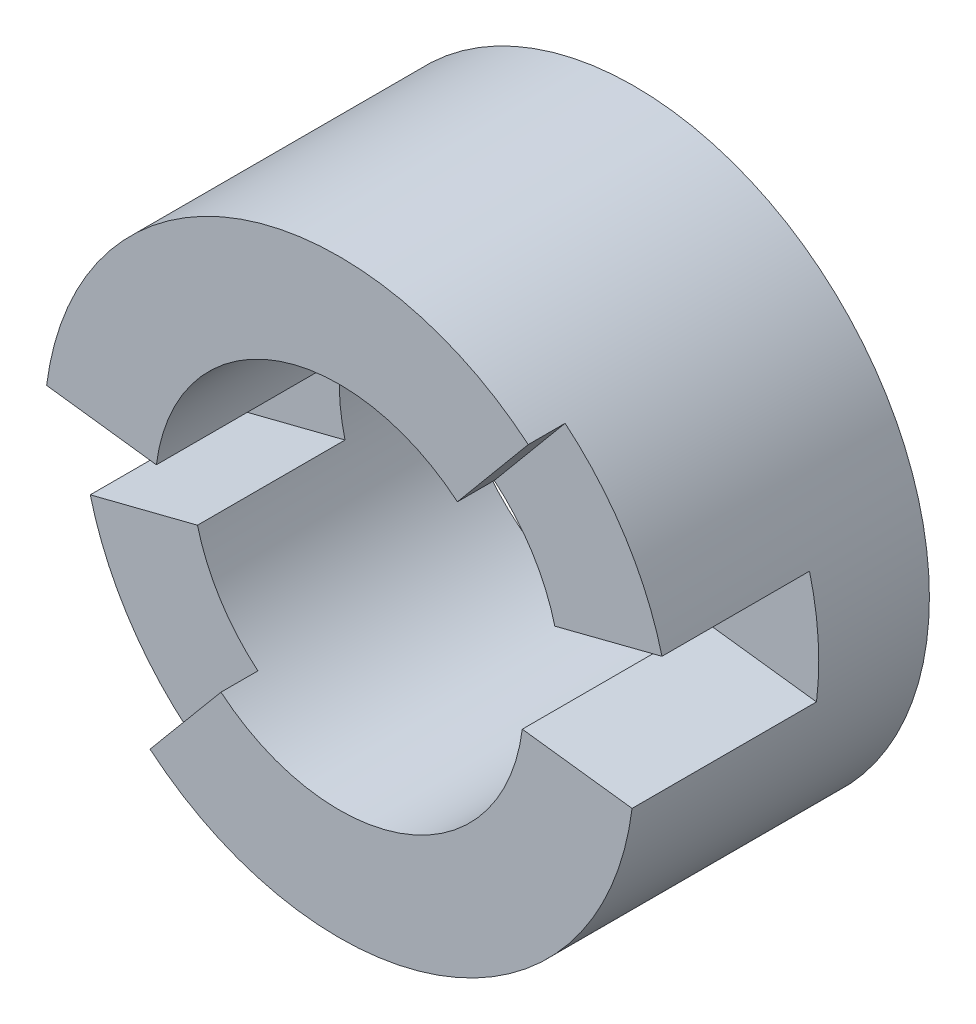
from build123d import *

# Parameters (mm, degrees)
SKETCH1_R                = 8
SKETCH1_R_2              = 5
BOSS_EXTRUDE1_DEPTH      = 8
WRAP2_SECTION_W          = 4
WRAP2_SECTION_H          = 1
WRAP2_ANGLE              = 57.295779513
WRAP2_SECTOR_2_SECTION_W = 4
WRAP2_SECTOR_2_SECTION_H = 1
WRAP2_SECTOR_2_ANGLE     = 57.295779513
WRAP2_SECTOR_3_SECTION_W = 4
WRAP2_SECTOR_3_SECTION_H = 4
WRAP2_SECTOR_3_ANGLE     = 21.485917317
WRAP2_SECTOR_4_SECTION_W = 4
WRAP2_SECTOR_4_SECTION_H = 4
WRAP2_SECTOR_4_ANGLE     = 21.485917317


with BuildPart() as part:
    # Sketch1 → Boss-Extrude1 (new body)
    with BuildSketch(Plane.XY):
        Circle(SKETCH1_R)
        Circle(SKETCH1_R_2, mode=Mode.SUBTRACT)
    extrude(amount=BOSS_EXTRUDE1_DEPTH)

    # Wrap2 section (on wrap section) → Wrap2 (revolve, cut)
    with BuildSketch(Plane(origin=(0, 0, 0), x_dir=(-0.6416078703161084, -0.7670328159527646, 0), z_dir=(0.7670328159527646, -0.6416078703161084, 0))):
        with Locations((6, -7.5)):
            Rectangle(WRAP2_SECTION_W, WRAP2_SECTION_H)
    revolve(axis=Axis((0, 0, 0), (0, 0, -1)), revolution_arc=WRAP2_ANGLE, mode=Mode.SUBTRACT)

    # Wrap2 sector 2 section (on wrap section) → Wrap2 sector 2 (revolve, cut)
    with BuildSketch(Plane(origin=(0, 0, 0), x_dir=(0.6403854395311468, 0.7680537017920687, 0), z_dir=(-0.7680537017920687, 0.6403854395311468, 0))):
        with Locations((6, -7.5)):
            Rectangle(WRAP2_SECTOR_2_SECTION_W, WRAP2_SECTOR_2_SECTION_H)
    revolve(axis=Axis((0, 0, 0), (0, 0, -1)), revolution_arc=WRAP2_SECTOR_2_ANGLE, mode=Mode.SUBTRACT)

    # Wrap2 sector 3 section (on wrap section) → Wrap2 sector 3 (revolve, cut)
    with BuildSketch(Plane(origin=(0, 0, 0), x_dir=(-0.9691091288804563, -0.24663230996883403, 0), z_dir=(0.24663230996883403, -0.9691091288804563, 0))):
        with Locations((6, -5)):
            Rectangle(WRAP2_SECTOR_3_SECTION_W, WRAP2_SECTOR_3_SECTION_H)
    revolve(axis=Axis((0, 0, 0), (0, 0, -1)), revolution_arc=WRAP2_SECTOR_3_ANGLE, mode=Mode.SUBTRACT)

    # Wrap2 sector 4 section (on wrap section) → Wrap2 sector 4 (revolve, cut)
    with BuildSketch(Plane(origin=(0, 0, 0), x_dir=(0.9687151001182653, 0.24817545165237268, 0), z_dir=(-0.24817545165237268, 0.9687151001182653, 0))):
        with Locations((6, -5)):
            Rectangle(WRAP2_SECTOR_4_SECTION_W, WRAP2_SECTOR_4_SECTION_H)
    revolve(axis=Axis((0, 0, 0), (0, 0, -1)), revolution_arc=WRAP2_SECTOR_4_ANGLE, mode=Mode.SUBTRACT)


solid = part.part
